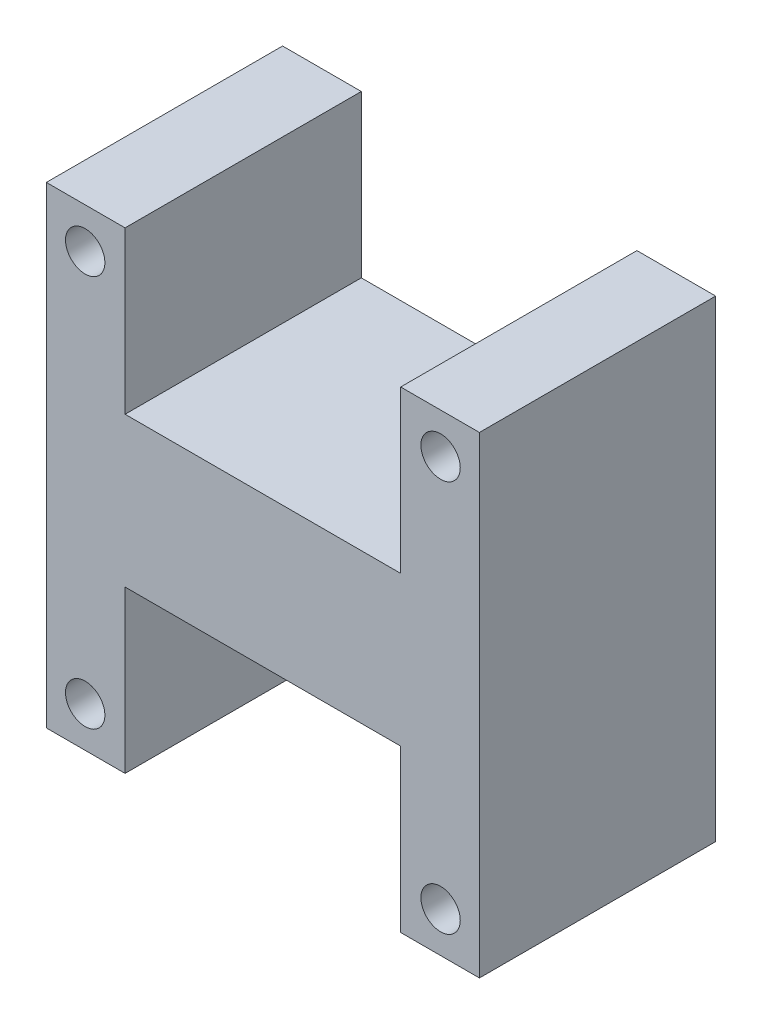
from build123d import *

# Parameters (mm, degrees)
SKETCH1_R           = 3.175
BOSS_EXTRUDE2_DEPTH = 38.1


with BuildPart() as part:
    # Sketch1 → Boss-Extrude2 (new body)
    with BuildSketch(Plane.XY):
        Polygon((0, 76.2), (0, 0), (12.7, 0), (12.7, 26.035), (57.15, 26.035), (57.15, 0), (69.85, 0), (69.85, 76.2), (57.15, 76.2), (57.15, 50.165), (12.7, 50.165), (12.7, 76.2), align=None)
        with Locations((6.265614618, 6.497674419)):
            Circle(SKETCH1_R, mode=Mode.SUBTRACT)
        with Locations((63.584385382, 6.497674419)):
            Circle(SKETCH1_R, mode=Mode.SUBTRACT)
        with Locations((6.265614618, 69.702325581)):
            Circle(SKETCH1_R, mode=Mode.SUBTRACT)
        with Locations((63.584385382, 69.702325581)):
            Circle(SKETCH1_R, mode=Mode.SUBTRACT)
    extrude(amount=BOSS_EXTRUDE2_DEPTH)


solid = part.part
